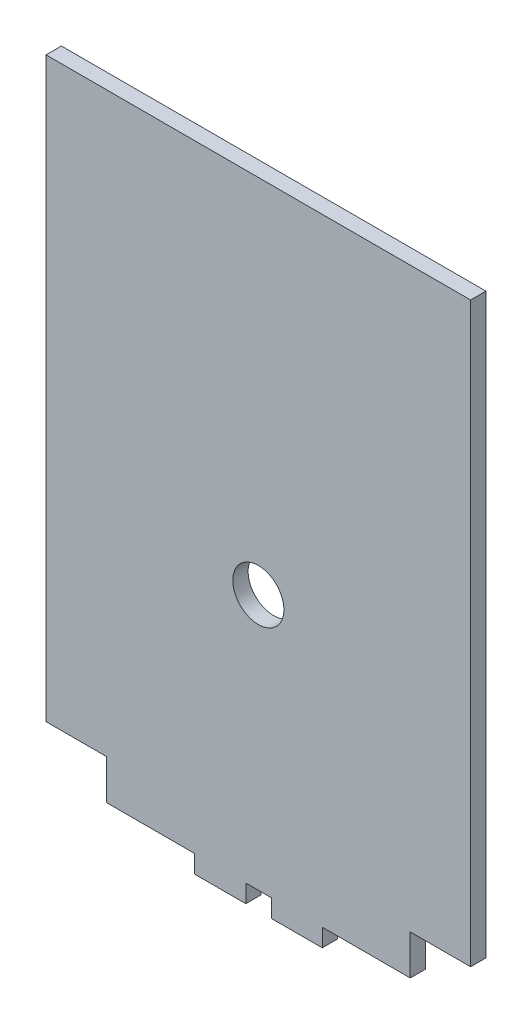
from build123d import *

# Parameters (mm, degrees)
MODEL_R                 = 5
SALIENTE_EXTRUIR1_DEPTH = 3


with BuildPart() as part:
    # Model → Saliente-Extruir1 (new body)
    with BuildSketch(Plane.XY):
        Polygon((51.452228979, -12.845067988), (64.29161116, -12.845071475), (93.152229006, -12.845079314), (93.152229006, -125.745072524), (81.352229006, -125.745072524), (81.352229006, -133.541965254), (64.152215459, -133.537426112), (64.152215459, -137.037426112), (54.202215459, -137.037426112), (54.202215459, -133.537426112), (49.202215459, -133.537426112), (49.202215459, -137.037426112), (39.152215459, -137.037426112), (39.152215459, -133.543892764), (21.952201913, -133.535518228), (21.95220415, -125.745072524), (10.152204277, -125.745072081), (10.152222671, -40.537066854), (10.152227654, -12.845056771), (38.62328624, -12.845064504), align=None)
        with Locations((51.652229006, -83.545079314)):
            Circle(MODEL_R, mode=Mode.SUBTRACT)
    extrude(amount=SALIENTE_EXTRUIR1_DEPTH)


solid = part.part
